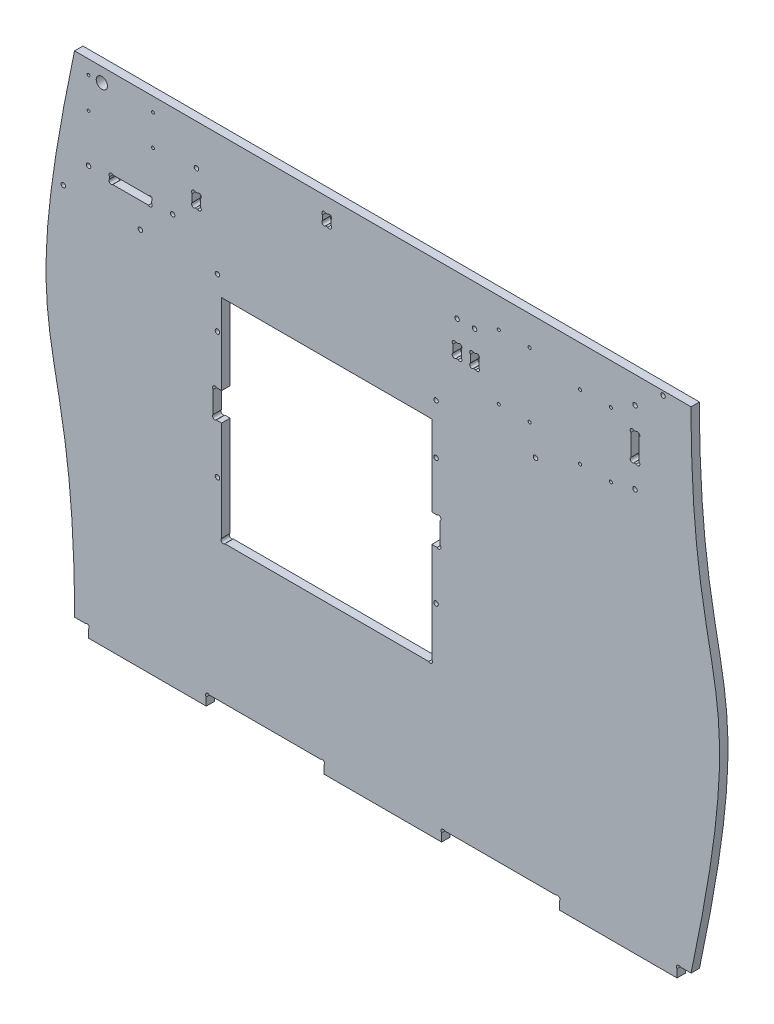
from build123d import *

# Parameters (mm, degrees)
ESQUISSE1_R        = 1.6
ESQUISSE1_R_2      = 1.1
ESQUISSE1_R_3      = 4
ESQUISSE1_R_4      = 1
BOSS_EXTRU_1_DEPTH = 6


with BuildPart() as part:
    # Esquisse1 → Boss.-Extru.1 (new body)
    with BuildSketch(Plane.XY):
        with BuildLine():
            Line((0, 0), (84, 0))
            Line((84, 0), (84, 5.7372583))
            ThreePointArc((84, 5.7372583), (84, 8), (86.2627417, 8))
            Line((86.2627417, 8), (165.7372583, 8))
            ThreePointArc((165.7372583, 8), (168, 8), (168, 5.7372583))
            Line((168, 5.7372583), (168, 0))
            Line((168, 0), (252, 0))
            Line((252, 0), (252, 5.7372583))
            ThreePointArc((252, 5.7372583), (252, 8), (254.2627417, 8))
            Line((254.2627417, 8), (333.7372583, 8))
            ThreePointArc((333.7372583, 8), (336, 8), (336, 5.7372583))
            Line((336, 5.7372583), (336, 0))
            Line((336, 0), (420, 0))
            Line((420, 0), (420, 5.7372583))
            ThreePointArc((420, 5.7372583), (420, 8), (422.2627417, 8))
            Line((422.2627417, 8), (430, 8))
            add(Edge.make_bspline(
                [(430, 8), (475.762038199, 224.87493493), (430, 170.541411889), (430, 358)],
                knots=[0, 0, 0, 0, 1, 1, 1, 1], degree=3))
            Line((430, 358), (-10, 358))
            add(Edge.make_bspline(
                [(-10, 358), (-55.762038199, 141.12506507), (-10, 195.458588109), (-10, 8)],
                knots=[0, 0, 0, 0, 1, 1, 1, 1], degree=3))
            Line((-10, 8), (-2.2627417, 8))
            ThreePointArc((-2.2627417, 8), (0, 8), (0, 5.7372583))
            Line((0, 5.7372583), (0, 0))
        make_face()
        with Locations((92, 271)):
            Circle(ESQUISSE1_R, mode=Mode.SUBTRACT)
        with Locations(Location((248, 271, 0), (0, 0, 180))):  # turned: the seam where the file's is
            Circle(ESQUISSE1_R, mode=Mode.SUBTRACT)
        with Locations((92, 145.5)):
            Circle(ESQUISSE1_R, mode=Mode.SUBTRACT)
        with Locations(Location((92, 235.5, 0), (0, 0, 180))):  # turned: the seam where the file's is
            Circle(ESQUISSE1_R, mode=Mode.SUBTRACT)
        with Locations((372.75, 329)):
            Circle(ESQUISSE1_R_2, mode=Mode.SUBTRACT)
        with Locations((350.75, 329)):
            Circle(ESQUISSE1_R_2, mode=Mode.SUBTRACT)
        with Locations((248, 235.5)):
            Circle(ESQUISSE1_R, mode=Mode.SUBTRACT)
        with Locations(Location((248, 145.5, 0), (0, 0, 180))):  # turned: the seam where the file's is
            Circle(ESQUISSE1_R, mode=Mode.SUBTRACT)
        with Locations((350.75, 283)):
            Circle(ESQUISSE1_R_2, mode=Mode.SUBTRACT)
        with Locations((319, 271)):
            Circle(ESQUISSE1_R, mode=Mode.SUBTRACT)
        with Locations((-18, 271)):
            Circle(ESQUISSE1_R, mode=Mode.SUBTRACT)
        with Locations((37, 271)):
            Circle(ESQUISSE1_R, mode=Mode.SUBTRACT)
        with Locations((390, 339)):
            Circle(ESQUISSE1_R, mode=Mode.SUBTRACT)
        with Locations(Location((390, 287, 0), (0, 0, 180))):  # turned: the seam where the file's is
            Circle(ESQUISSE1_R, mode=Mode.SUBTRACT)
        with Locations((410, 355)):
            Circle(ESQUISSE1_R, mode=Mode.SUBTRACT)
        with Locations((9.5, 348)):
            Circle(ESQUISSE1_R_3, mode=Mode.SUBTRACT)
        with Locations((46, 348)):
            Circle(ESQUISSE1_R_4, mode=Mode.SUBTRACT)
        with Locations((0, 348)):
            Circle(ESQUISSE1_R_4, mode=Mode.SUBTRACT)
        with Locations((0, 326)):
            Circle(ESQUISSE1_R_4, mode=Mode.SUBTRACT)
        with Locations((46, 326)):
            Circle(ESQUISSE1_R_4, mode=Mode.SUBTRACT)
        with Locations((372.75, 283)):
            Circle(ESQUISSE1_R_2, mode=Mode.SUBTRACT)
        with Locations((314.75, 337)):
            Circle(ESQUISSE1_R_2, mode=Mode.SUBTRACT)
        with Locations((292.75, 337)):
            Circle(ESQUISSE1_R_2, mode=Mode.SUBTRACT)
        with Locations((292.75, 291)):
            Circle(ESQUISSE1_R_2, mode=Mode.SUBTRACT)
        with Locations((314.75, 291)):
            Circle(ESQUISSE1_R_2, mode=Mode.SUBTRACT)
        with Locations((263, 329)):
            Circle(ESQUISSE1_R, mode=Mode.SUBTRACT)
        with Locations(Location((77, 329, 0), (0, 0, 180))):  # turned: the seam where the file's is
            Circle(ESQUISSE1_R, mode=Mode.SUBTRACT)
        with Locations(Location((275.5, 329, 0), (0, 0, 180))):  # turned: the seam where the file's is
            Circle(ESQUISSE1_R, mode=Mode.SUBTRACT)
        with Locations((60, 292)):
            Circle(ESQUISSE1_R, mode=Mode.SUBTRACT)
        with Locations(Location((0, 292, 0), (0, 0, 180))):  # turned: the seam where the file's is
            Circle(ESQUISSE1_R, mode=Mode.SUBTRACT)
        with BuildLine():
            Line((91.2627417, 180.5), (95, 180.5))
            Line((95, 180.5), (95, 109.2627417))
            ThreePointArc((95, 109.2627417), (95, 107), (97.2627417, 107))
            Line((97.2627417, 107), (242.7372583, 107))
            ThreePointArc((242.7372583, 107), (245, 107), (245, 109.2627417))
            Line((245, 109.2627417), (245, 180.5))
            Line((245, 180.5), (248.7372583, 180.5))
            ThreePointArc((248.7372583, 180.5), (251, 180.5), (251, 182.7627417))
            Line((251, 182.7627417), (251, 198.2372583))
            ThreePointArc((251, 198.2372583), (251, 200.5), (248.7372583, 200.5))
            Line((248.7372583, 200.5), (245, 200.5))
            Line((245, 200.5), (245, 258))
            Line((245, 258), (95, 258))
            Line((95, 258), (95, 200.5))
            Line((95, 200.5), (91.2627417, 200.5))
            ThreePointArc((91.2627417, 200.5), (89, 200.5), (89, 198.2372583))
            Line((89, 198.2372583), (89, 182.7627417))
            ThreePointArc((89, 182.7627417), (89, 180.5), (91.2627417, 180.5))
        make_face(mode=Mode.SUBTRACT)
        with BuildLine():
            Line((389.2627417, 323), (390.7372583, 323))
            ThreePointArc((390.7372583, 323), (393, 323), (393, 320.7372583))
            Line((393, 320.7372583), (393, 305.2627417))
            ThreePointArc((393, 305.2627417), (393, 303), (390.7372583, 303))
            Line((390.7372583, 303), (389.2627417, 303))
            ThreePointArc((389.2627417, 303), (387, 303), (387, 305.2627417))
            Line((387, 305.2627417), (387, 320.7372583))
            ThreePointArc((387, 320.7372583), (387, 323), (389.2627417, 323))
        make_face(mode=Mode.SUBTRACT)
        with BuildLine():
            Line((262.2627417, 314), (263.7372583, 314))
            ThreePointArc((263.7372583, 314), (266, 314), (266, 311.7372583))
            Line((266, 311.7372583), (266, 306.2627417))
            ThreePointArc((266, 306.2627417), (266, 304), (263.7372583, 304))
            Line((263.7372583, 304), (262.2627417, 304))
            ThreePointArc((262.2627417, 304), (260, 304), (260, 306.2627417))
            Line((260, 306.2627417), (260, 311.7372583))
            ThreePointArc((260, 311.7372583), (260, 314), (262.2627417, 314))
        make_face(mode=Mode.SUBTRACT)
        with BuildLine():
            Line((74, 306.2627417), (74, 311.7372583))
            ThreePointArc((74, 311.7372583), (74, 314), (76.2627417, 314))
            Line((76.2627417, 314), (77.7372583, 314))
            ThreePointArc((77.7372583, 314), (80, 314), (80, 311.7372583))
            Line((80, 311.7372583), (80, 306.2627417))
            ThreePointArc((80, 306.2627417), (80, 304), (77.7372583, 304))
            Line((77.7372583, 304), (76.2627417, 304))
            ThreePointArc((76.2627417, 304), (74, 304), (74, 306.2627417))
        make_face(mode=Mode.SUBTRACT)
        with BuildLine():
            Line((272.5, 306.2627417), (272.5, 311.7372583))
            ThreePointArc((272.5, 311.7372583), (272.5, 314), (274.7627417, 314))
            Line((274.7627417, 314), (276.2372583, 314))
            ThreePointArc((276.2372583, 314), (278.5, 314), (278.5, 311.7372583))
            Line((278.5, 311.7372583), (278.5, 306.2627417))
            ThreePointArc((278.5, 306.2627417), (278.5, 304), (276.2372583, 304))
            Line((276.2372583, 304), (274.7627417, 304))
            ThreePointArc((274.7627417, 304), (272.5, 304), (272.5, 306.2627417))
        make_face(mode=Mode.SUBTRACT)
        with BuildLine():
            Line((15, 292.7372583), (15, 291.2627417))
            ThreePointArc((15, 291.2627417), (15, 289), (17.2627417, 289))
            Line((17.2627417, 289), (42.7372583, 289))
            ThreePointArc((42.7372583, 289), (45, 289), (45, 291.2627417))
            Line((45, 291.2627417), (45, 292.7372583))
            ThreePointArc((45, 292.7372583), (45, 295), (42.7372583, 295))
            Line((42.7372583, 295), (17.2627417, 295))
            ThreePointArc((17.2627417, 295), (15, 295), (15, 292.7372583))
        make_face(mode=Mode.SUBTRACT)
        with BuildLine():
            Line((170.7372583, 339.4), (169.2627417, 339.4))
            ThreePointArc((169.2627417, 339.4), (167, 339.4), (167, 341.6627417))
            Line((167, 341.6627417), (167, 345.1372583))
            ThreePointArc((167, 345.1372583), (167, 347.4), (169.2627417, 347.4))
            Line((169.2627417, 347.4), (170.7372583, 347.4))
            ThreePointArc((170.7372583, 347.4), (173, 347.4), (173, 345.1372583))
            Line((173, 345.1372583), (173, 341.6627417))
            ThreePointArc((173, 341.6627417), (173, 339.4), (170.7372583, 339.4))
        make_face(mode=Mode.SUBTRACT)
    extrude(amount=BOSS_EXTRU_1_DEPTH)


solid = part.part
